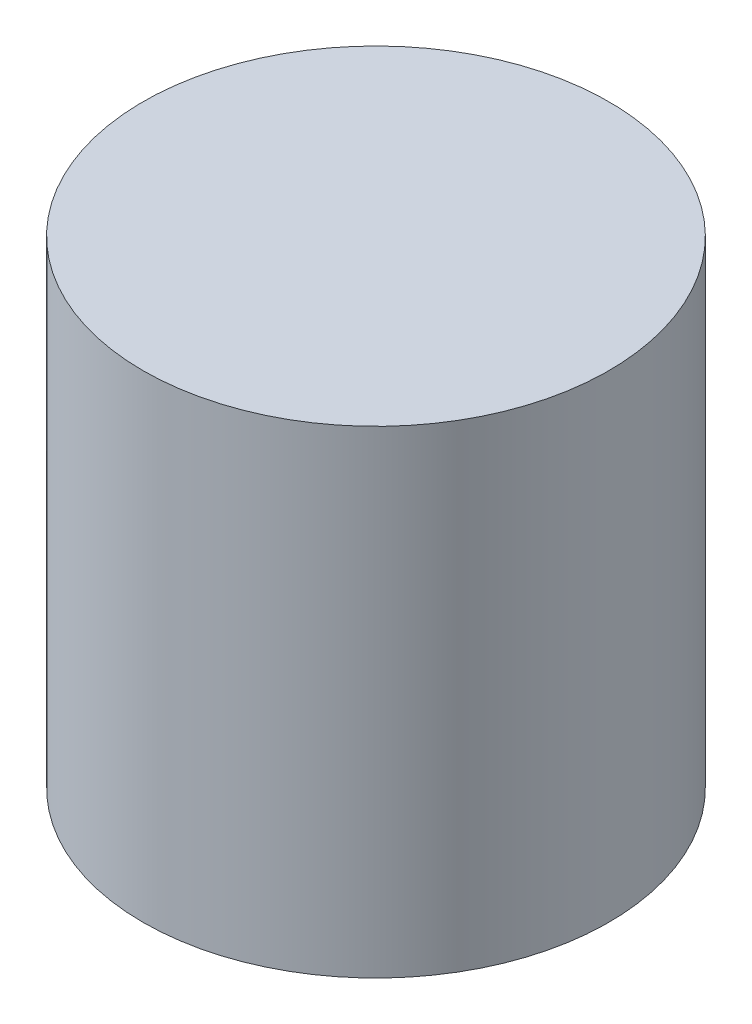
from build123d import *

# Parameters (mm, degrees)
SKETCH1_R           = 9.75
BOSS_EXTRUDE1_DEPTH = 20


with BuildPart() as part:
    # Sketch1 → Boss-Extrude1 (new body)
    with BuildSketch(Plane(origin=(0, 0, 0), x_dir=(1, 0, 0), z_dir=(0, 1, 0))):
        Circle(SKETCH1_R)
    extrude(amount=BOSS_EXTRUDE1_DEPTH)


solid = part.part
